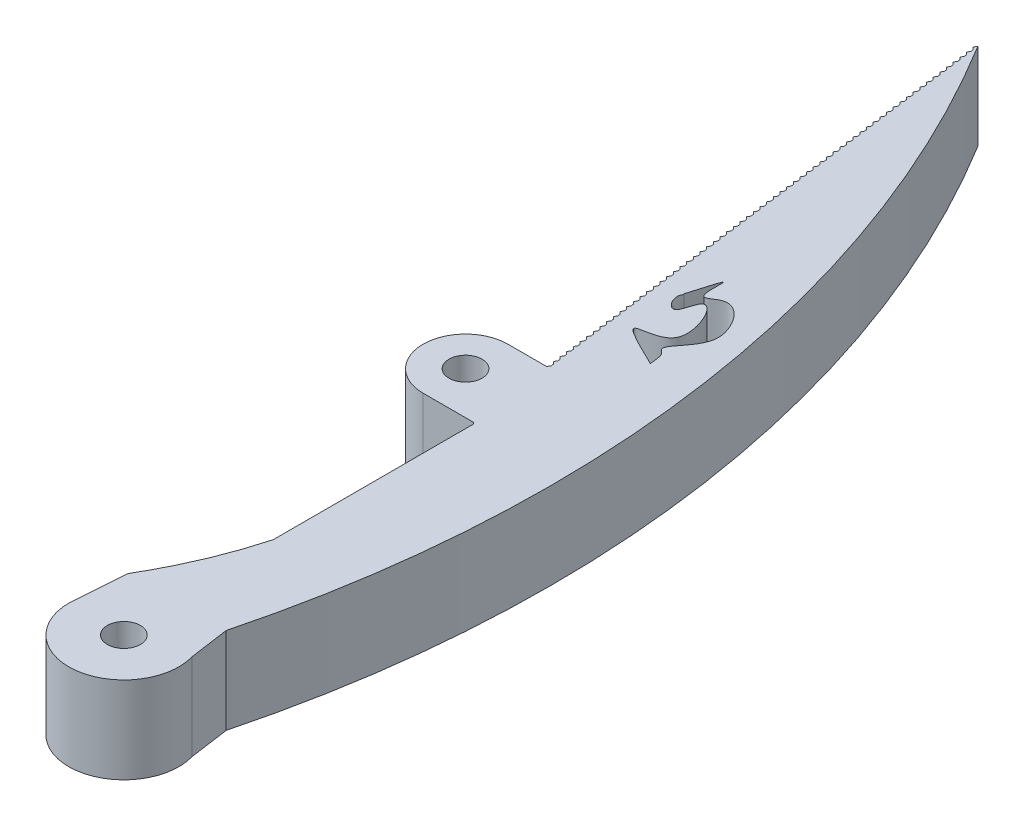
from build123d import *

# Parameters (mm, degrees)
BOSS_EXTRUDE1_DEPTH  = 7.85
BOSS_EXTRUDE9_DEPTH  = 7.5
LPATTERN1_COUNT      = 76
LPATTERN1_PITCH      = 0.7
SKETCH2_R            = 1.5
CUT_EXTRUDE1_DEPTH   = 81.043179336
CUT_EXTRUDE3_DEPTH   = 10
SKETCH11_R           = 1.5
BOSS_EXTRUDE10_DEPTH = 7.5


with BuildPart() as part:
    # Sketch1 → Boss-Extrude1 (new body)
    with BuildSketch(Plane(origin=(0, 0, 0), x_dir=(1, 0, 0), z_dir=(0, 1, 0))):
        with BuildLine():
            Line((-7.066469929, 25.840417654), (-7.066469929, 7.686602927))
            add(Edge.make_bspline(
                [(-7.066469929, 7.686602927), (-7.915113614, 4.522566315), (-9.226292644, 1.431607927), (-11.000007022, -1.586272238)],
                knots=[0.751594771, 0.751594771, 0.751594771, 0.751594771, 1, 1, 1, 1], degree=3))
            Line((-11.000007022, -1.586272238), (-11.354847987, -6.586272238))
            ThreePointArc((-11.354847987, -6.586272238), (-5.650325753, -11.536388239), (-1.553388617, -5.191285527))
            Line((-1.553388617, -5.191285527), (-2.066469929, -1.586272238))
            ThreePointArc((-2.066469929, -1.586272238), (0.172043045, 39.615512077), (-13.874181744, 78.413727762))
            Line((-13.874181744, 78.413727762), (-7.066469929, 25.840417654))
        make_face()
    extrude(amount=BOSS_EXTRUDE1_DEPTH)

    # Sketch3 → Boss-Extrude9 (add)
    with BuildSketch(Plane(origin=(0, 7.85, 0), x_dir=(1, 0, 0), z_dir=(0, 1, 0))):
        Polygon((-7.066469917, 25.840417557), (-7.278601909, 26.052549633), (-7.12749843, 26.311717029), align=None)
    boss_extrude9 = extrude(amount=-BOSS_EXTRUDE9_DEPTH)

    # LPattern1: Boss-Extrude9 ×76
    with Locations(*[Vector(-0.1284177289724115, 0, -0.9917201656140548) * (i * LPATTERN1_PITCH) for i in range(1, LPATTERN1_COUNT)]):
        add(boss_extrude9)

    # Sketch2 → Cut-Extrude1 (cut, through all)
    with BuildSketch(Plane(origin=(0, 7.85, 0), x_dir=(1, 0, 0), z_dir=(0, 1, 0))):
        with Locations(Location((-6.354847987, -6.586272238, 0), (0, 0, 270))):
            Circle(SKETCH2_R)
    extrude(amount=-CUT_EXTRUDE1_DEPTH, mode=Mode.SUBTRACT)

    # Sketch10 → Cut-Extrude3 (cut)
    with BuildSketch(Plane.XZ):
        with BuildLine():
            add(Edge.make_bspline(
                [(-3.796065351, -38.610825347), (-10.714968821, -41.908301283), (-1.836177713, -38.720994778), (-6.256427569, -47.846471722), (-6.690229987, -42.848152605), (-8.169552993, -44.962261836), (-7.672470355, -45.591467477), (-7.771814047, -45.560304775)],
                knots=[0, 0, 0, 0, 0.433330256, 0.72620864, 0.863352883, 0.98985149, 1, 1, 1, 1], degree=3))
            add(Edge.make_bspline(
                [(-3.796065351, -38.610825347), (-3.873710354, -39.087693605), (-3.82101762, -39.826908313), (-4.706669902, -40.36859361), (-3.125639789, -42.195001461), (-2.135375146, -44.246306498), (-4.692290826, -47.84355546), (-7.630049989, -44.994772829), (-6.186487973, -51.190073514), (-7.771814047, -45.560304775)],
                knots=[0, 0, 0, 0, 0.107516691, 0.111296189, 0.210603665, 0.423358143, 0.673551605, 0.750062418, 1, 1, 1, 1], degree=3))
        make_face()
    extrude(amount=-CUT_EXTRUDE3_DEPTH, mode=Mode.SUBTRACT)

    # Sketch11 → Boss-Extrude10 (add)
    with BuildSketch(Plane(origin=(0, 7.85, 0), x_dir=(1, 0, 0), z_dir=(0, 1, 0))):
        with BuildLine():
            Line((-11.778987996, 25.981507322), (1.270148042, 25.981507322))
            ThreePointArc((1.270148042, 25.981507322), (1.143607271, 29.834164671), (0.873596233, 33.679431275))
            Line((0.873596233, 33.679431275), (-11.778987996, 33.679431275))
            ThreePointArc((-11.778987996, 33.679431275), (-15.627949972, 29.830469298), (-11.778987996, 25.981507322))
        make_face()
        with Locations(Location((-11.778987996, 29.830469298, 0), (0, 0, 270))):
            Circle(SKETCH11_R, mode=Mode.SUBTRACT)
    extrude(amount=-BOSS_EXTRUDE10_DEPTH)


solid = part.part
